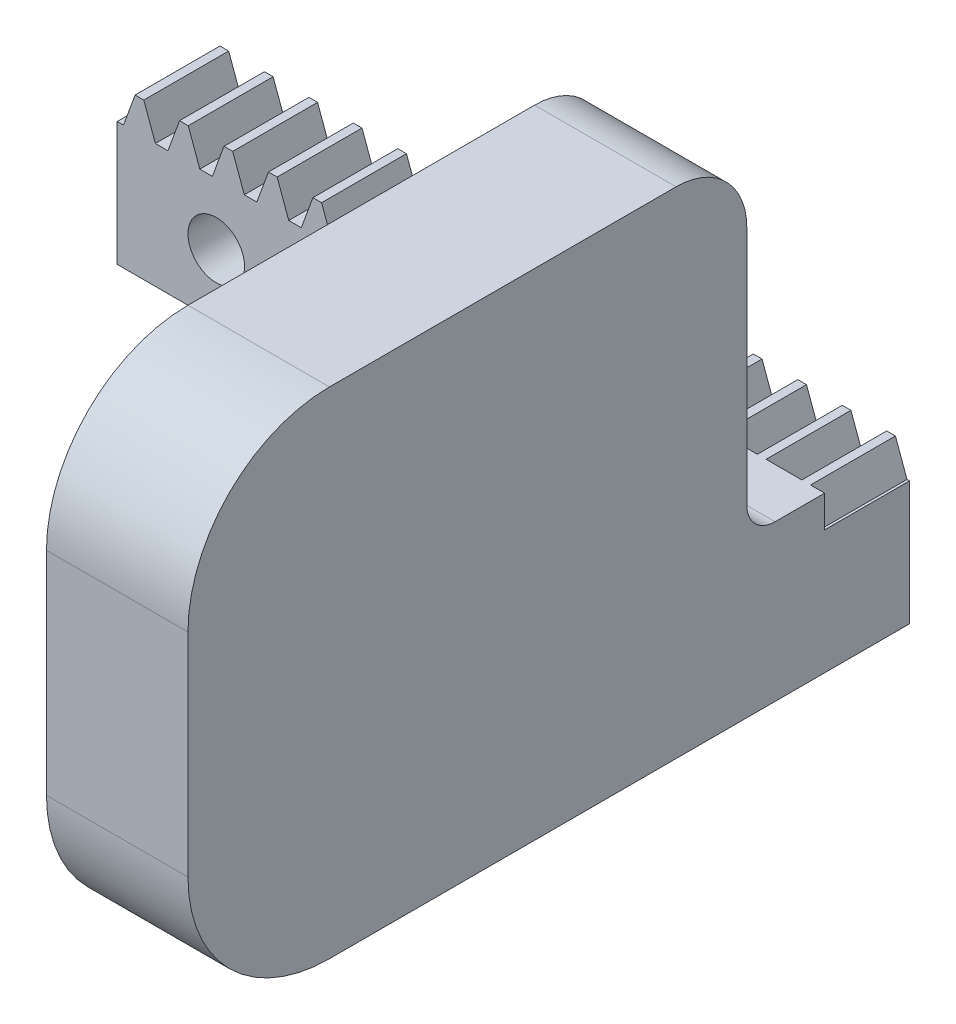
from build123d import *

# Parameters (mm, degrees)
BLANKSKE_W          = 50
BLANKSKE_H          = 11
BLANK_DEPTH         = 6
TOOTHCUTSIM_DEPTH   = 52.546095875
TEETHCUTS_COUNT     = 17
TEETHCUTS_PITCH     = 3.14159265
SKETCH1_W           = 10
SKETCH1_H           = 35
BOSS_EXTRUDE1_DEPTH = 45
FILLET1_R           = 10
SKETCH2_R           = 2
CUT_EXTRUDE1_DEPTH  = 25
SKETCH4_W           = 5.5
SKETCH4_H           = 30
CUT_EXTRUDE2_DEPTH  = 10
FILLET3_R           = 2
FILLET4_R           = 5


with BuildPart() as part:
    # BlankSke → Blank (new body)
    with BuildSketch(Plane.XY):
        with Locations((25, 5.5)):
            Rectangle(BLANKSKE_W, BLANKSKE_H)
    extrude(amount=-BLANK_DEPTH)

    # TooCutSkeSim → ToothCutSim (cut, through all)
    with BuildSketch(Plane.XY):
        Polygon((0.44443537, 8.75), (-0.44443537, 8.75), (-1.272613241, 11.0254), (1.272613241, 11.0254), align=None)
    toothcutsim = extrude(amount=-TOOTHCUTSIM_DEPTH, mode=Mode.SUBTRACT)

    # TeethCuts: ToothCutSim ×17
    with Locations(*[(i * TEETHCUTS_PITCH, 0, 0) for i in range(1, TEETHCUTS_COUNT)]):
        add(toothcutsim, mode=Mode.SUBTRACT)

    # Sketch1 → Boss-Extrude1 (add)
    with BuildSketch(Plane.XY):
        with Locations((45, 17.5)):
            Rectangle(SKETCH1_W, SKETCH1_H)
    extrude(amount=BOSS_EXTRUDE1_DEPTH)

    # Fillet1
    fillet1_edges = [part.edges().sort_by_distance(p)[0] for p in [
        (45, 0, 45),
        (45, 35, 45),
    ]]
    fillet(fillet1_edges, radius=FILLET1_R)

    # Sketch2 → Cut-Extrude1 (cut)
    with BuildSketch(Plane.XY):
        with Locations((7, 4.375)):
            Circle(SKETCH2_R)
        with Locations((32, 4.375)):
            Circle(SKETCH2_R)
    extrude(amount=-CUT_EXTRUDE1_DEPTH, mode=Mode.SUBTRACT)

    # Sketch4 → Cut-Extrude2 (cut)
    with BuildSketch(Plane.ZY.offset(-40)):
        with Locations((2.75, 26)):
            Rectangle(SKETCH4_W, SKETCH4_H)
    extrude(amount=-CUT_EXTRUDE2_DEPTH, mode=Mode.SUBTRACT)

    # Fillet3
    fillet3_edges = [part.edges().sort_by_distance(p)[0] for p in [
        (45, 11, 5.5),
    ]]
    fillet(fillet3_edges, radius=FILLET3_R)

    # Fillet4
    fillet4_edges = [part.edges().sort_by_distance(p)[0] for p in [
        (45, 35, 5.5),
    ]]
    fillet(fillet4_edges, radius=FILLET4_R)


solid = part.part
